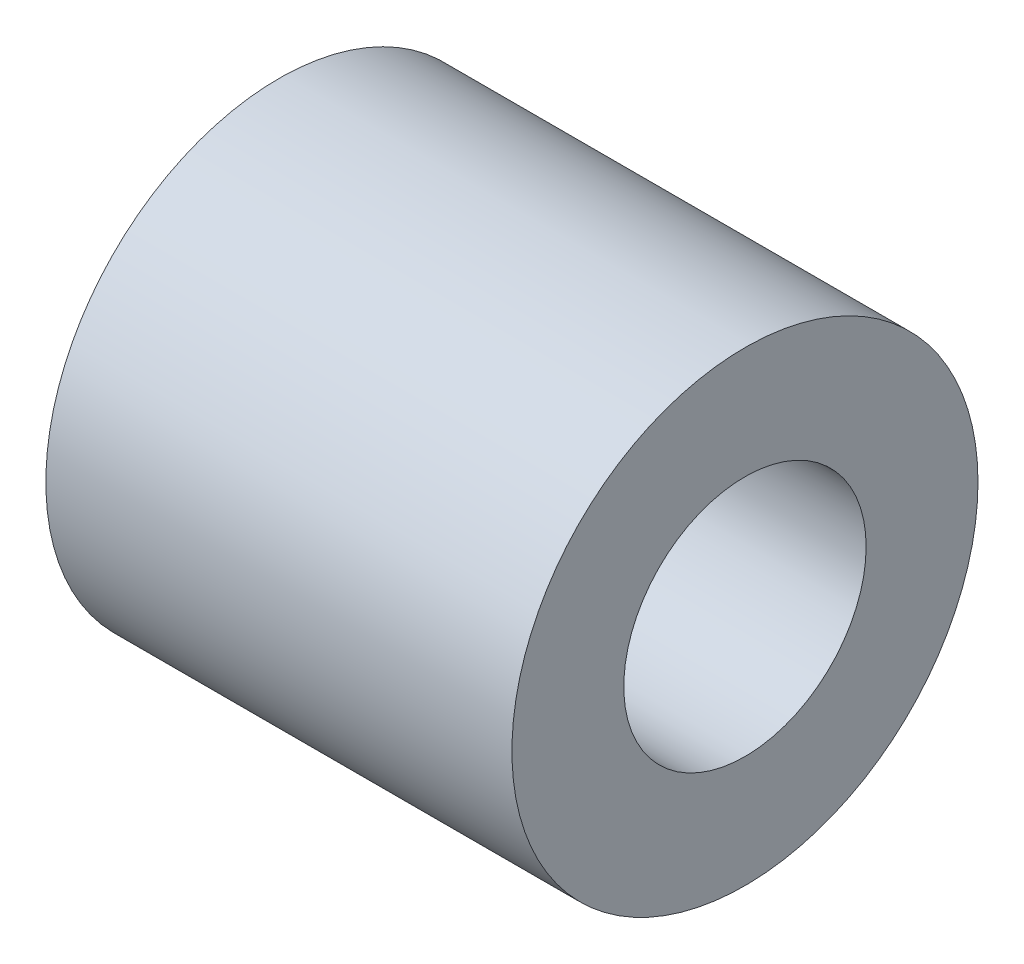
from build123d import *

# Parameters (mm, degrees)
SKETCH1_R           = 3.175
BOSS_EXTRUDE1_DEPTH = 6.35
SKETCH2_R           = 1.651
CUT_EXTRUDE1_DEPTH  = 7.35


with BuildPart() as part:
    # Sketch1 → Boss-Extrude1 (new body)
    with BuildSketch(Plane(origin=(0, 0, 0), x_dir=(0, 0, -1), z_dir=(1, 0, 0))):
        Circle(SKETCH1_R)
    extrude(amount=BOSS_EXTRUDE1_DEPTH)

    # Sketch2 → Cut-Extrude1 (cut, through all)
    with BuildSketch(Plane(origin=(6.35, 0, 0), x_dir=(0, 0, -1), z_dir=(1, 0, 0))):
        Circle(SKETCH2_R)
    extrude(amount=-CUT_EXTRUDE1_DEPTH, mode=Mode.SUBTRACT)


solid = part.part
